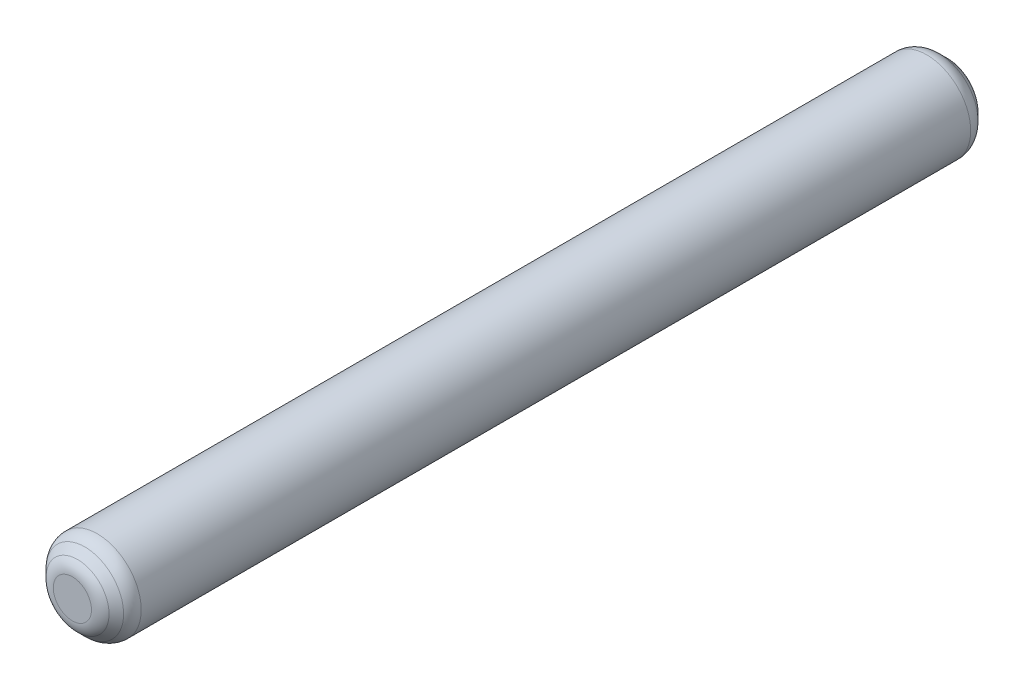
from build123d import *

# Parameters (mm, degrees)
SKETCH2_R           = 0.5
BOSS_EXTRUDE1_DEPTH = 10
CHAMFER1_SIZE       = 0.2
FILLET1_R           = 0.2
FILLET2_R           = 0.2
FILLET3_R           = 0.2


with BuildPart() as part:
    # Sketch2 → Boss-Extrude1 (new body)
    with BuildSketch(Plane.XY):
        Circle(SKETCH2_R)
    extrude(amount=BOSS_EXTRUDE1_DEPTH)

    # Chamfer1
    chamfer1_edges = [part.edges().sort_by_distance(p)[0] for p in [
        (-0.5, 0, 0),
        (-0.5, 0, 10),
    ]]
    chamfer(chamfer1_edges, length=CHAMFER1_SIZE)

    # Fillet1
    fillet1_edges = [part.edges().sort_by_distance(p)[0] for p in [
        (-0.5, 0, 0.2),
    ]]
    fillet(fillet1_edges, radius=FILLET1_R)

    # Fillet2
    fillet2_edges = [part.edges().sort_by_distance(p)[0] for p in [
        (-0.3, 0, 0),
    ]]
    fillet(fillet2_edges, radius=FILLET2_R)

    # Fillet3
    fillet3_edges = [part.edges().sort_by_distance(p)[0] for p in [
        (-0.5, 0, 9.8),
        (-0.3, 0, 10),
    ]]
    fillet(fillet3_edges, radius=FILLET3_R)


solid = part.part
